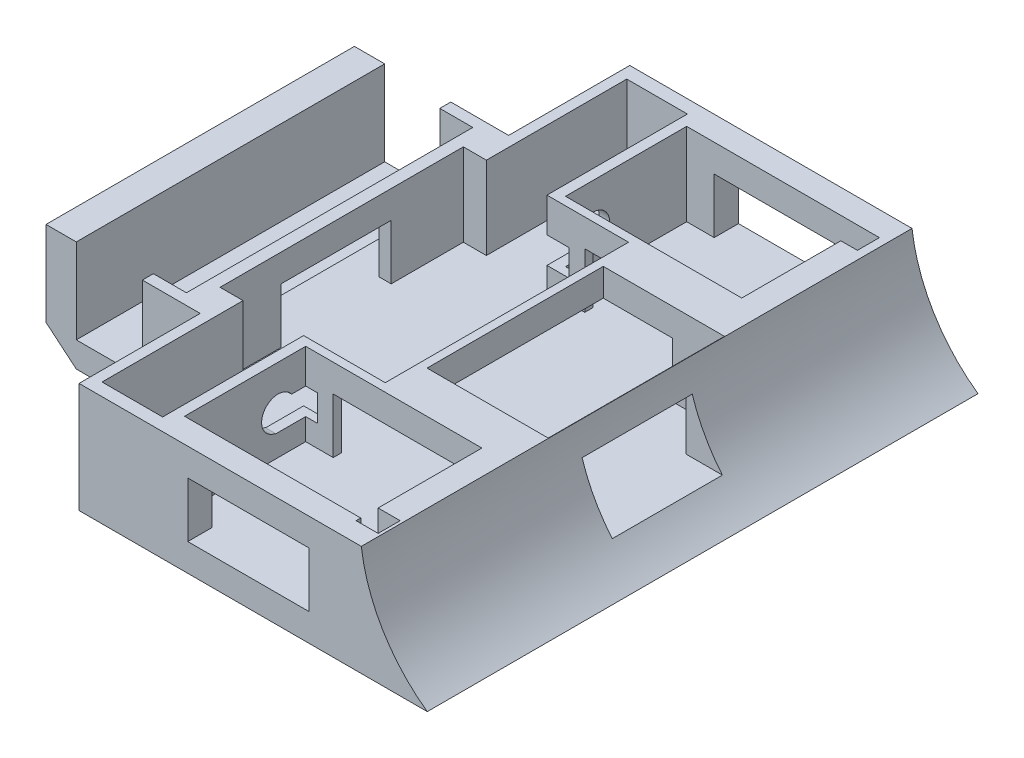
from build123d import *

# Parameters (mm, degrees)
SKETCH1_W           = 100
SKETCH1_H           = 100
BOSS_EXTRUDE2_DEPTH = 40
SKETCH3_W           = 20
SKETCH3_H           = 10
CUT_EXTRUDE3_DEPTH  = 100
SKETCH4_R           = 29.179887526
CUT_EXTRUDE5_DEPTH  = 100
SKETCH5_W           = 60
SKETCH5_H           = 20
CUT_EXTRUDE6_DEPTH  = 100
SKETCH6_W           = 22
SKETCH6_H           = 32
CUT_EXTRUDE7_DEPTH  = 15
SKETCH7_W           = 22
SKETCH7_H           = 10
CUT_EXTRUDE9_DEPTH  = 100
SKETCH9_W           = 32
SKETCH9_H           = 22
CUT_EXTRUDE10_DEPTH = 15
SKETCH10_W          = 32
SKETCH10_H          = 22
CUT_EXTRUDE11_DEPTH = 15
SKETCH11_W          = 33
SKETCH11_H          = 33
CUT_EXTRUDE13_DEPTH = 22
SKETCH12_W          = 33
SKETCH12_H          = 33
CUT_EXTRUDE14_DEPTH = 22
SKETCH13_W          = 30
SKETCH13_H          = 20
CUT_EXTRUDE15_DEPTH = 100
SKETCH14_W          = 12
SKETCH14_H          = 16
CUT_EXTRUDE17_DEPTH = 80
SKETCH15_W          = 24
SKETCH15_H          = 52
CUT_EXTRUDE18_DEPTH = 15
SKETCH16_W          = 30
SKETCH16_H          = 44.18
CUT_EXTRUDE19_DEPTH = 15
SKETCH17_W          = 11
SKETCH17_H          = 26
CUT_EXTRUDE20_DEPTH = 15
SKETCH18_W          = 11
SKETCH18_H          = 26
CUT_EXTRUDE22_DEPTH = 15
SKETCH19_W          = 11
SKETCH19_H          = 17
CUT_EXTRUDE26_DEPTH = 2.2
SKETCH20_R          = 2.5
CUT_EXTRUDE32_DEPTH = 17
SKETCH21_W          = 4
SKETCH21_H          = 12
CUT_EXTRUDE33_DEPTH = 4
SKETCH23_W          = 11
SKETCH23_H          = 17
CUT_EXTRUDE34_DEPTH = 2.2
SKETCH24_R          = 2.5
CUT_EXTRUDE35_DEPTH = 17
SKETCH25_W          = 4
SKETCH25_H          = 12
CUT_EXTRUDE36_DEPTH = 3
SKETCH26_R          = 3
CUT_EXTRUDE37_DEPTH = 3
SKETCH27_R          = 3
CUT_EXTRUDE38_DEPTH = 3
SKETCH28_W          = 17
SKETCH28_H          = 11
CUT_EXTRUDE39_DEPTH = 2.2
SKETCH29_R          = 3
CUT_EXTRUDE40_DEPTH = 4
SKETCH30_W          = 4
SKETCH30_H          = 4.8
CUT_EXTRUDE43_DEPTH = 7
SKETCH31_W          = 4
SKETCH31_H          = 4.8
CUT_EXTRUDE44_DEPTH = 7
CUT_EXTRUDE45_DEPTH = 100
SKETCH34_W          = 5
SKETCH34_H          = 20
CUT_EXTRUDE46_DEPTH = 100
CUT_EXTRUDE47_DEPTH = 100
SKETCH36_W          = 5.5
SKETCH36_H          = 15.404877169
BOSS_EXTRUDE3_DEPTH = 55
SKETCH37_W          = 20.232210009
SKETCH37_H          = 11
CUT_EXTRUDE48_DEPTH = 3
SKETCH38_W          = 40
SKETCH38_H          = 86
CUT_EXTRUDE53_DEPTH = 1


with BuildPart() as part:
    # Sketch1 → Boss-Extrude2 (new body)
    with BuildSketch(Plane(origin=(0, 0, 0), x_dir=(1, 0, 0), z_dir=(0, 1, 0))):
        Rectangle(SKETCH1_W, SKETCH1_H)
    extrude(amount=BOSS_EXTRUDE2_DEPTH)

    # Sketch3 → Cut-Extrude3 (cut)
    with BuildSketch(Plane(origin=(50, 0, 0), x_dir=(0, 0, -1), z_dir=(1, 0, 0))):
        with Locations((-1.010205144, 10)):
            Rectangle(SKETCH3_W, SKETCH3_H)
    extrude(amount=-CUT_EXTRUDE3_DEPTH, mode=Mode.SUBTRACT)

    # Sketch4 → Cut-Extrude5 (cut)
    with BuildSketch(Plane.XY.offset(50)):
        with Locations((63.191438408, 23.747323898)):
            Circle(SKETCH4_R)
    extrude(amount=-CUT_EXTRUDE5_DEPTH, mode=Mode.SUBTRACT)

    # Sketch5 → Cut-Extrude6 (cut)
    with BuildSketch(Plane.XY.offset(50)):
        with Locations((8.956827713, 30)):
            Rectangle(SKETCH5_W, SKETCH5_H)
    extrude(amount=-CUT_EXTRUDE6_DEPTH, mode=Mode.SUBTRACT)

    # Sketch6 → Cut-Extrude7 (cut)
    with BuildSketch(Plane(origin=(0, 20, 0), x_dir=(1, 0, 0), z_dir=(0, 1, 0))):
        with Locations((23.190442589, 0)):
            Rectangle(SKETCH6_W, SKETCH6_H)
    extrude(amount=-CUT_EXTRUDE7_DEPTH, mode=Mode.SUBTRACT)

    # Sketch7 → Cut-Extrude9 (cut)
    with BuildSketch(Plane.XY.offset(50)):
        with Locations((13.743053617, 10)):
            Rectangle(SKETCH7_W, SKETCH7_H)
    extrude(amount=-CUT_EXTRUDE9_DEPTH, mode=Mode.SUBTRACT)

    # Sketch9 → Cut-Extrude10 (cut)
    with BuildSketch(Plane(origin=(0, 20, 0), x_dir=(1, 0, 0), z_dir=(0, 1, 0))):
        with Locations((13.743053617, -34.588860887)):
            Rectangle(SKETCH9_W, SKETCH9_H)
    extrude(amount=-CUT_EXTRUDE10_DEPTH, mode=Mode.SUBTRACT)

    # Sketch10 → Cut-Extrude11 (cut)
    with BuildSketch(Plane(origin=(0, 20, 0), x_dir=(1, 0, 0), z_dir=(0, 1, 0))):
        with Locations((13.743053617, 34.59)):
            Rectangle(SKETCH10_W, SKETCH10_H)
    extrude(amount=-CUT_EXTRUDE11_DEPTH, mode=Mode.SUBTRACT)

    # Sketch11 → Cut-Extrude13 (cut)
    with BuildSketch(Plane.XY.offset(50)):
        with Locations((-33.5, 16.5)):
            Rectangle(SKETCH11_W, SKETCH11_H)
    extrude(amount=-CUT_EXTRUDE13_DEPTH, mode=Mode.SUBTRACT)

    # Sketch12 → Cut-Extrude14 (cut)
    with BuildSketch(Plane(origin=(0, 0, -50), x_dir=(-1, 0, 0), z_dir=(0, 0, -1))):
        with Locations((33.5, 16.5)):
            Rectangle(SKETCH12_W, SKETCH12_H)
    extrude(amount=-CUT_EXTRUDE14_DEPTH, mode=Mode.SUBTRACT)

    # Sketch13 → Cut-Extrude15 (cut)
    with BuildSketch(Plane(origin=(0, 0, -50), x_dir=(-1, 0, 0), z_dir=(0, 0, -1))):
        with Locations((36.043172287, 30)):
            Rectangle(SKETCH13_W, SKETCH13_H)
    extrude(amount=-CUT_EXTRUDE15_DEPTH, mode=Mode.SUBTRACT)

    # Sketch14 → Cut-Extrude17 (cut)
    with BuildSketch(Plane.XY.offset(28)):
        with Locations((-33.5, 12.595122831)):
            Rectangle(SKETCH14_W, SKETCH14_H)
    extrude(amount=-CUT_EXTRUDE17_DEPTH, mode=Mode.SUBTRACT)

    # Sketch15 → Cut-Extrude18 (cut)
    with BuildSketch(Plane(origin=(0, 20, 0), x_dir=(1, 0, 0), z_dir=(0, 1, 0))):
        with Locations((-33.5, 0)):
            Rectangle(SKETCH15_W, SKETCH15_H)
    extrude(amount=-CUT_EXTRUDE18_DEPTH, mode=Mode.SUBTRACT)

    # Sketch16 → Cut-Extrude19 (cut)
    with BuildSketch(Plane(origin=(0, 20, 0), x_dir=(1, 0, 0), z_dir=(0, 1, 0))):
        with Locations((-4.309557411, 0.001139113)):
            Rectangle(SKETCH16_W, SKETCH16_H)
    extrude(amount=-CUT_EXTRUDE19_DEPTH, mode=Mode.SUBTRACT)

    # Sketch17 → Cut-Extrude20 (cut)
    with BuildSketch(Plane(origin=(0, 20, 0), x_dir=(1, 0, 0), z_dir=(0, 1, 0))):
        with Locations((-9.626946383, 34.59)):
            Rectangle(SKETCH17_W, SKETCH17_H)
    extrude(amount=-CUT_EXTRUDE20_DEPTH, mode=Mode.SUBTRACT)

    # Sketch18 → Cut-Extrude22 (cut)
    with BuildSketch(Plane(origin=(0, 20, 0), x_dir=(1, 0, 0), z_dir=(0, 1, 0))):
        with Locations((-9.63, -34.691148393)):
            Rectangle(SKETCH18_W, SKETCH18_H)
    extrude(amount=-CUT_EXTRUDE22_DEPTH, mode=Mode.SUBTRACT)

    # Sketch19 → Cut-Extrude26 (cut)
    with BuildSketch(Plane(origin=(0, 0, 0), x_dir=(-1, 0, 0), z_dir=(0, -1, 0))):
        with Locations((-37.734715737, -36.5)):
            Rectangle(SKETCH19_W, SKETCH19_H)
    extrude(amount=-CUT_EXTRUDE26_DEPTH, mode=Mode.SUBTRACT)

    # Sketch20 → Cut-Extrude32 (cut)
    with BuildSketch(Plane(origin=(0, 0, 0), x_dir=(-1, 0, 0), z_dir=(0, -1, 0))):
        with Locations((-32.234715737, -45)):
            Circle(SKETCH20_R)
    extrude(amount=-CUT_EXTRUDE32_DEPTH, mode=Mode.SUBTRACT)

    # Sketch21 → Cut-Extrude33 (cut)
    with BuildSketch(Plane.ZY.offset(-29.743053617)):
        with Locations((44.433350435, 14)):
            Rectangle(SKETCH21_W, SKETCH21_H)
    extrude(amount=-CUT_EXTRUDE33_DEPTH, mode=Mode.SUBTRACT)

    # Sketch23 → Cut-Extrude34 (cut)
    with BuildSketch(Plane(origin=(0, 0, 0), x_dir=(-1, 0, 0), z_dir=(0, -1, 0))):
        with Locations((-37.734715737, 36.5)):
            Rectangle(SKETCH23_W, SKETCH23_H)
    extrude(amount=-CUT_EXTRUDE34_DEPTH, mode=Mode.SUBTRACT)

    # Sketch24 → Cut-Extrude35 (cut)
    with BuildSketch(Plane.XZ):
        with Locations((32.234715737, -45)):
            Circle(SKETCH24_R)
    extrude(amount=-CUT_EXTRUDE35_DEPTH, mode=Mode.SUBTRACT)

    # Sketch25 → Cut-Extrude36 (cut)
    with BuildSketch(Plane.ZY.offset(-29.743053617)):
        with Locations((-43.59, 14)):
            Rectangle(SKETCH25_W, SKETCH25_H)
    extrude(amount=-CUT_EXTRUDE36_DEPTH, mode=Mode.SUBTRACT)

    # Sketch26 → Cut-Extrude37 (cut)
    with BuildSketch(Plane(origin=(-2.256946383, 0, 0), x_dir=(0, 0, -1), z_dir=(1, 0, 0))):
        with Locations((-28.588860887, 12)):
            Circle(SKETCH26_R)
    extrude(amount=-CUT_EXTRUDE37_DEPTH, mode=Mode.SUBTRACT)

    # Sketch27 → Cut-Extrude38 (cut)
    with BuildSketch(Plane(origin=(-2.256946383, 0, 0), x_dir=(0, 0, -1), z_dir=(1, 0, 0))):
        with Locations((28.59, 12)):
            Circle(SKETCH27_R)
    extrude(amount=-CUT_EXTRUDE38_DEPTH, mode=Mode.SUBTRACT)

    # Sketch28 → Cut-Extrude39 (cut)
    with BuildSketch(Plane.XZ):
        with Locations((-40.055873336, 0)):
            Rectangle(SKETCH28_W, SKETCH28_H)
    extrude(amount=-CUT_EXTRUDE39_DEPTH, mode=Mode.SUBTRACT)

    # Sketch29 → Cut-Extrude40 (cut)
    with BuildSketch(Plane(origin=(0, 2.2, 0), x_dir=(-1, 0, 0), z_dir=(0, -1, 0))):
        with Locations((47.799920192, -0.070169229)):
            Circle(SKETCH29_R)
    extrude(amount=-CUT_EXTRUDE40_DEPTH, mode=Mode.SUBTRACT)

    # Sketch30 → Cut-Extrude43 (cut)
    with BuildSketch(Plane.XY.offset(-22.091139113)):
        with Locations((-2.126946383, 11.349361099)):
            Rectangle(SKETCH30_W, SKETCH30_H)
    extrude(amount=-CUT_EXTRUDE43_DEPTH, mode=Mode.SUBTRACT)

    # Sketch31 → Cut-Extrude44 (cut)
    with BuildSketch(Plane(origin=(0, 0, 22.088860887), x_dir=(-1, 0, 0), z_dir=(0, 0, -1))):
        with Locations((2.13, 11.35)):
            Rectangle(SKETCH31_W, SKETCH31_H)
    extrude(amount=-CUT_EXTRUDE44_DEPTH, mode=Mode.SUBTRACT)

    # Sketch33 → Cut-Extrude45 (cut)
    with BuildSketch(Plane(origin=(0, 0, -28), x_dir=(-1, 0, 0), z_dir=(0, 0, -1))):
        Polygon((45, 0), (50, 5), (50, 0), align=None)
    extrude(amount=-CUT_EXTRUDE45_DEPTH, mode=Mode.SUBTRACT)

    # Sketch34 → Cut-Extrude46 (cut)
    with BuildSketch(Plane.XY.offset(28)):
        with Locations((-47.5, 10)):
            Rectangle(SKETCH34_W, SKETCH34_H)
    extrude(amount=-CUT_EXTRUDE46_DEPTH, mode=Mode.SUBTRACT)

    # Sketch35 → Cut-Extrude47 (cut)
    with BuildSketch(Plane.XY.offset(28)):
        Polygon((-45, 4.595122831), (-39.5, 0), (-45, 0), align=None)
    extrude(amount=-CUT_EXTRUDE47_DEPTH, mode=Mode.SUBTRACT)

    # Sketch36 → Boss-Extrude3 (add)
    with BuildSketch(Plane.XY.offset(28)):
        with Locations((-42.25, 12.297561416)):
            Rectangle(SKETCH36_W, SKETCH36_H)
    extrude(amount=-BOSS_EXTRUDE3_DEPTH)

    # Sketch37 → Cut-Extrude48 (cut)
    with BuildSketch(Plane(origin=(0, 0, 0), x_dir=(-1, 0, 0), z_dir=(0, -1, 0))):
        with Locations((32.017121667, 0)):
            Rectangle(SKETCH37_W, SKETCH37_H)
    extrude(amount=-CUT_EXTRUDE48_DEPTH, mode=Mode.SUBTRACT)

    # Sketch38 → Cut-Extrude53 (cut)
    with BuildSketch(Plane(origin=(0, 3, 0), x_dir=(-1, 0, 0), z_dir=(0, -1, 0))):
        with Locations((-6.777878387, 0)):
            Rectangle(SKETCH38_W, SKETCH38_H)
    extrude(amount=-CUT_EXTRUDE53_DEPTH, mode=Mode.SUBTRACT)


solid = part.part
